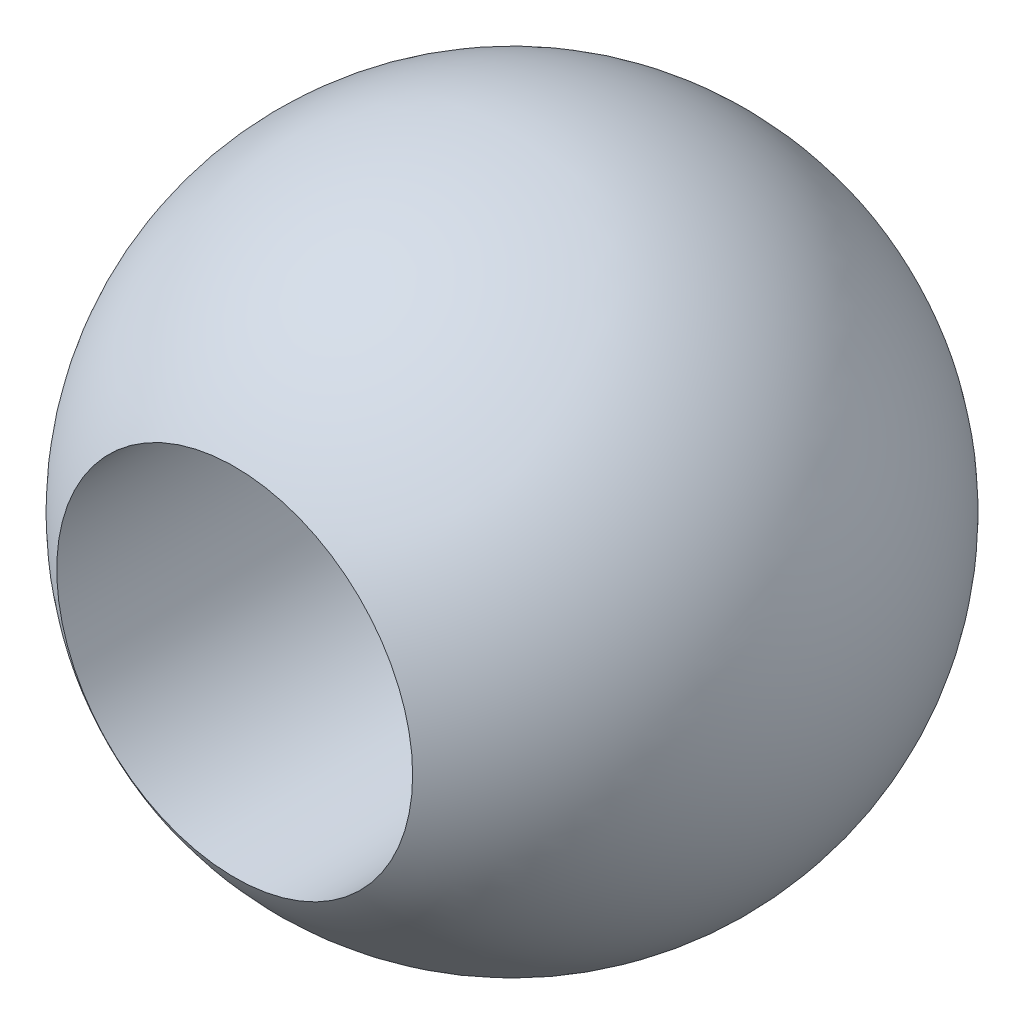
from build123d import *


with BuildPart() as part:
    # Sketch1 → Revolve1 (revolve)
    with BuildSketch(Plane(origin=(0, 0, 0), x_dir=(1, 0, 0), z_dir=(0, 1, 0))):
        with BuildLine():
            Line((0, 0), (3.429, 0))
            Line((3.429, 0), (3.429, -5.344572855))
            ThreePointArc((3.429, -5.344572855), (6.093461152, 1.786681613), (0, 6.35))
            Line((0, 6.35), (0, 0))
        make_face()
    revolve(axis=Axis((0, 0, 0), (0, 0, -1)))


solid = part.part
